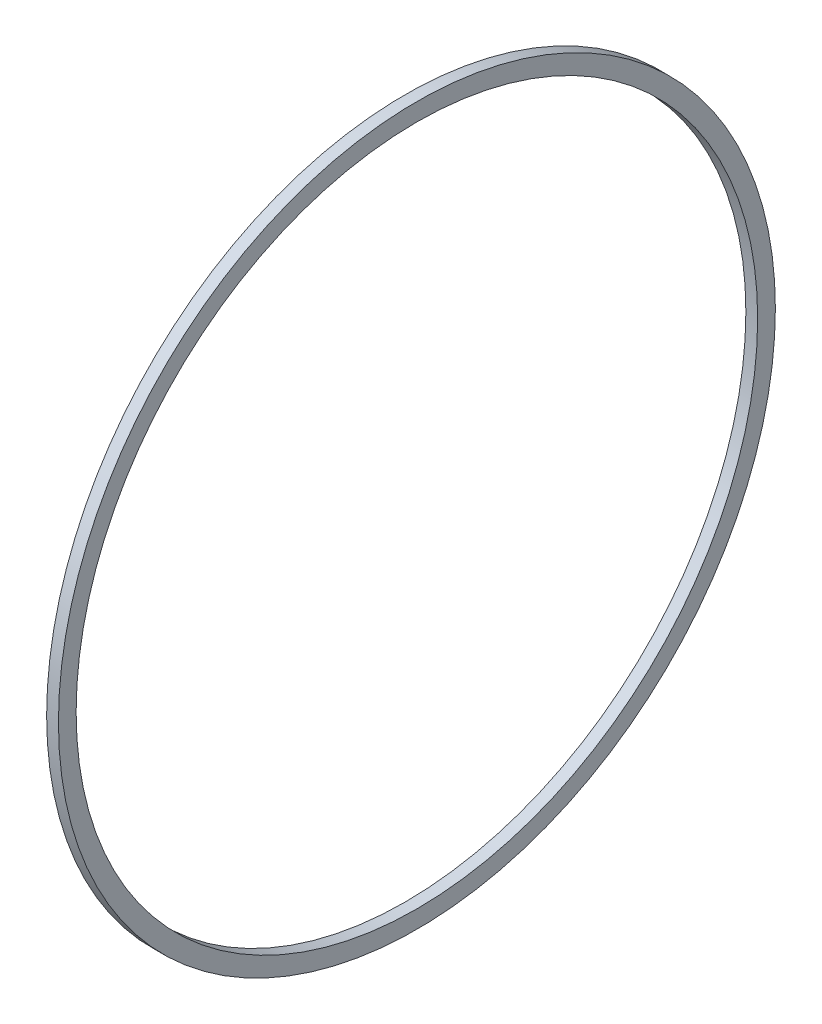
from build123d import *

# Parameters (mm, degrees)
SKETCH1_R           = 60.75
SKETCH1_R_2         = 57.75
BOSS_EXTRUDE1_DEPTH = 2


with BuildPart() as part:
    # Sketch1 → Boss-Extrude1 (new body)
    with BuildSketch(Plane(origin=(0, 0, 0), x_dir=(0, 0, -1), z_dir=(1, 0, 0))):
        Circle(SKETCH1_R)
        Circle(SKETCH1_R_2, mode=Mode.SUBTRACT)
    extrude(amount=BOSS_EXTRUDE1_DEPTH)


solid = part.part
